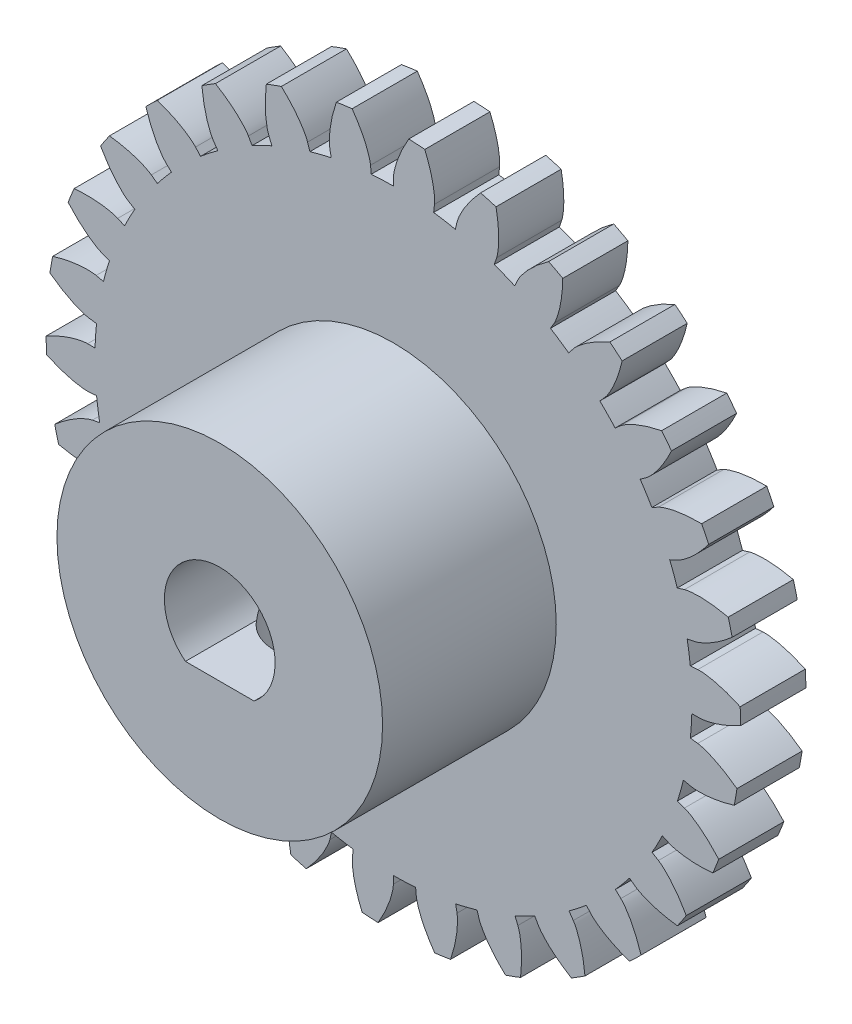
from build123d import *

# Parameters (mm, degrees)
EXTRUDE_1_DEPTH          = 3
SKETCH_4_R               = 7.5
EXTRUDE_2_DEPTH          = 8
CUT_EXTRUDE_1_DEPTH      = 15
CUT_EXTRUDE_1_DEPTH_BACK = 4.0000001
CUT_EXTRUDE_2_REACH      = 25.484
SKETCH_6_R               = 2


with BuildPart() as part:
    # 草图2 → 凸台-拉伸1 (new body)
    with BuildSketch(Plane.XY):
        with BuildLine():
            Line((1.89051353, 13.968033449), (1.851773853, 13.624736093))
            ThreePointArc((1.851773853, 13.624736093), (2.353137788, 13.547148872), (2.851298212, 13.451118857))
            Line((2.851298212, 13.451118857), (2.930596225, 13.787371237))
            add(Edge.make_bspline(
                [(2.930596225, 13.787371237), (2.933219885, 13.79849651), (2.941339291, 13.829509854), (2.959683399, 13.887352304), (2.993800918, 13.98038017), (3.04335636, 14.096749327), (3.114269634, 14.244351202), (3.206492503, 14.414330406), (3.316759861, 14.596676231), (3.446131284, 14.78988522), (3.583347507, 14.977782742), (3.727632125, 15.160449042), (3.854396241, 15.310151049), (3.946384196, 15.413194585), (4.000432021, 15.472051391), (4.015191609, 15.488002981)],
                knots=[0, 0, 0, 0, 0, 0.005376748, 0.015083688, 0.02853182, 0.046610139, 0.064854849, 0.092110525, 0.119476175, 0.146842495, 0.174208853, 0.201574955, 0.228941013, 0.239165463, 0.239165463, 0.239165463, 0.239165463, 0.239165463], degree=4))
            ThreePointArc((4.015191609, 15.488002981), (4.370978567, 15.391378963), (4.724444799, 15.28658305))
            add(Edge.make_bspline(
                [(4.753318726, 13.269738541), (4.756933997, 13.280582207), (4.766326776, 13.311233928), (4.781122088, 13.370084197), (4.800991416, 13.467158389), (4.819995031, 13.59220392), (4.837244285, 13.755045774), (4.848125921, 13.948124973), (4.850156172, 14.16120892), (4.841643416, 14.393575465), (4.823665136, 14.625546481), (4.796924027, 14.856782165), (4.767762618, 15.050765268), (4.743663456, 15.18677624), (4.728617371, 15.26525494), (4.724444799, 15.28658305)],
                knots=[0, 0, 0, 0, 0, 0.005376748, 0.015083688, 0.02853182, 0.046610139, 0.064854849, 0.092110525, 0.119476175, 0.146842495, 0.174208853, 0.201574955, 0.228941013, 0.239165463, 0.239165463, 0.239165463, 0.239165463, 0.239165463], degree=4))
            Line((4.753318726, 13.269738541), (4.644050069, 12.941997487))
            ThreePointArc((4.644050069, 12.941997487), (5.118326709, 12.76186631), (5.58563537, 12.564361405))
            Line((5.58563537, 12.564361405), (5.733111332, 12.876778879))
            add(Edge.make_bspline(
                [(5.733111332, 12.876778879), (5.737990733, 12.887115549), (5.752380747, 12.915763058), (5.782350115, 12.968527557), (5.835063664, 13.05242911), (5.907730709, 13.155952166), (6.007782513, 13.285584887), (6.133330755, 13.432675425), (6.279100336, 13.588110684), (6.44581509, 13.750199761), (6.619098901, 13.905462414), (6.798209014, 14.054138558), (6.953327827, 14.174213476), (7.06472958, 14.255879892), (7.129833348, 14.302213361), (7.147586926, 14.31474768)],
                knots=[0, 0, 0, 0, 0, 0.005376748, 0.015083688, 0.02853182, 0.046610139, 0.064854849, 0.092110525, 0.119476175, 0.146842495, 0.174208853, 0.201574955, 0.228941013, 0.239165463, 0.239165463, 0.239165463, 0.239165463, 0.239165463], degree=4))
            ThreePointArc((7.147586926, 14.31474768), (7.475509822, 14.14626286), (7.799463673, 13.970267227))
            add(Edge.make_bspline(
                [(7.408381084, 11.991492383), (7.414171878, 12.001347432), (7.429732253, 12.02937647), (7.456439911, 12.083864601), (7.496057906, 12.174686424), (7.540644674, 12.293048337), (7.591373716, 12.448745383), (7.642160985, 12.63534292), (7.688449514, 12.843348358), (7.728434503, 13.072407039), (7.759078578, 13.303046825), (7.780998428, 13.534789244), (7.792805621, 13.730596348), (7.797511354, 13.868645652), (7.799110701, 13.948537661), (7.799463673, 13.970267227)],
                knots=[0, 0, 0, 0, 0, 0.005376748, 0.015083688, 0.02853182, 0.046610139, 0.064854849, 0.092110525, 0.119476175, 0.146842495, 0.174208853, 0.201574955, 0.228941013, 0.239165463, 0.239165463, 0.239165463, 0.239165463, 0.239165463], degree=4))
            Line((7.408381084, 11.991492383), (7.233359013, 11.693631488))
            ThreePointArc((7.233359013, 11.693631488), (7.659820192, 11.418828951), (8.075853459, 11.128481069))
            Line((8.075853459, 11.128481069), (8.285061963, 11.403409496))
            add(Edge.make_bspline(
                [(8.285061963, 11.403409496), (8.291983852, 11.412505799), (8.312015562, 11.437535439), (8.352300383, 11.482915926), (8.421306129, 11.554024265), (8.513908878, 11.640176765), (8.638726469, 11.746174761), (8.792113022, 11.86394807), (8.967013995, 11.985679496), (9.163785847, 12.109564592), (9.365563911, 12.225406653), (9.571671547, 12.333594781), (9.748365621, 12.418794758), (9.874312381, 12.47551484), (9.947626746, 12.507299978), (9.967598396, 12.515869215)],
                knots=[0, 0, 0, 0, 0, 0.005376748, 0.015083688, 0.02853182, 0.046610139, 0.064854849, 0.092110525, 0.119476175, 0.146842495, 0.174208853, 0.201574955, 0.228941013, 0.239165463, 0.239165463, 0.239165463, 0.239165463, 0.239165463], degree=4))
            ThreePointArc((9.967598396, 12.515869215), (10.253325427, 12.282887189), (10.53360856, 12.04338369))
            add(Edge.make_bspline(
                [(9.739661639, 10.189160466), (9.74737487, 10.197596185), (9.768422779, 10.221777537), (9.80587553, 10.269522138), (9.863510695, 10.350122241), (9.931731961, 10.456627552), (10.013723688, 10.598375084), (10.102196942, 10.77033575), (10.190720718, 10.964171844), (10.277455917, 11.179911696), (10.355383053, 11.399140188), (10.425005861, 11.621261086), (10.477265624, 11.810334482), (10.510570589, 11.9443887), (10.52874547, 12.022202354), (10.53360856, 12.04338369)],
                knots=[0, 0, 0, 0, 0, 0.005376748, 0.015083688, 0.02853182, 0.046610139, 0.064854849, 0.092110525, 0.119476175, 0.146842495, 0.174208853, 0.201574955, 0.228941013, 0.239165463, 0.239165463, 0.239165463, 0.239165463, 0.239165463], degree=4))
            Line((9.739661639, 10.189160466), (9.506535458, 9.934197682))
            ThreePointArc((9.506535458, 9.934197682), (9.866542778, 9.576733974), (10.213118, 9.20623271))
            Line((10.213118, 9.20623271), (10.47491563, 9.431656397))
            add(Edge.make_bspline(
                [(10.47491563, 9.431656397), (10.483577487, 9.439114783), (10.508375411, 9.459432639), (10.557215046, 9.495445767), (10.639497106, 9.550653118), (10.747988375, 9.615669785), (10.892116624, 9.693400433), (11.066637761, 9.776709256), (11.263026115, 9.859416601), (11.481255189, 9.939683342), (11.702708837, 10.011041958), (11.926806103, 10.074013728), (12.117353059, 10.120615118), (12.252340349, 10.149909926), (12.33066112, 10.165757569), (12.351977987, 10.169987208)],
                knots=[0, 0, 0, 0, 0, 0.005376748, 0.015083688, 0.02853182, 0.046610139, 0.064854849, 0.092110525, 0.119476175, 0.146842495, 0.174208853, 0.201574955, 0.228941013, 0.239165463, 0.239165463, 0.239165463, 0.239165463, 0.239165463], degree=4))
            ThreePointArc((12.351977987, 10.169987208), (12.583021509, 9.882690408), (12.807384206, 9.590146495))
            add(Edge.make_bspline(
                [(11.645272245, 7.941513344), (11.654570808, 7.948161051), (11.680186355, 7.967437877), (11.726747334, 8.006352279), (11.799880737, 8.073208052), (11.888754904, 8.163201967), (11.998425883, 8.284804936), (12.120718417, 8.434613225), (12.247608527, 8.605808408), (12.377303191, 8.798800565), (12.499107599, 8.997036426), (12.613390512, 9.199828053), (12.703818843, 9.373904326), (12.764267455, 9.498104647), (12.798223539, 9.570439115), (12.807384206, 9.590146495)],
                knots=[0, 0, 0, 0, 0, 0.005376748, 0.015083688, 0.02853182, 0.046610139, 0.064854849, 0.092110525, 0.119476175, 0.146842495, 0.174208853, 0.201574955, 0.228941013, 0.239165463, 0.239165463, 0.239165463, 0.239165463, 0.239165463], degree=4))
            Line((11.645272245, 7.941513344), (11.364230687, 7.740591767))
            ThreePointArc((11.364230687, 7.740591767), (11.642050099, 7.316089769), (11.904020277, 6.881627805))
            Line((11.904020277, 6.881627805), (12.20696522, 7.047694656))
            add(Edge.make_bspline(
                [(12.20696522, 7.047694656), (12.216988481, 7.053189157), (12.24546883, 7.06790724), (12.300728752, 7.092979065), (12.392691005, 7.1298726), (12.512329205, 7.170911894), (12.669469016, 7.216977993), (12.857497326, 7.262181333), (13.066789947, 7.30224989), (13.296938586, 7.335390234), (13.528389232, 7.35914669), (13.760682002, 7.374149935), (13.956754023, 7.380116033), (14.09488225, 7.380705244), (14.174786435, 7.379922773), (14.196516868, 7.379627959)],
                knots=[0, 0, 0, 0, 0, 0.005376748, 0.015083688, 0.02853182, 0.046610139, 0.064854849, 0.092110525, 0.119476175, 0.146842495, 0.174208853, 0.201574955, 0.228941013, 0.239165463, 0.239165463, 0.239165463, 0.239165463, 0.239165463], degree=4))
            ThreePointArc((14.196516868, 7.379627959), (14.362779172, 7.050572634), (14.521415706, 6.71777388))
            add(Edge.make_bspline(
                [(13.041928573, 5.346783981), (13.052406077, 5.35135314), (13.08146974, 5.364882949), (13.135104009, 5.393266406), (13.220539368, 5.44345593), (13.326182208, 5.513005285), (13.458739293, 5.609149059), (13.609506336, 5.730257629), (13.769217072, 5.871329849), (13.936202922, 6.033139627), (14.096561165, 6.201718999), (14.250509472, 6.376318389), (14.37515422, 6.527789571), (14.460104583, 6.636707843), (14.508357827, 6.700401763), (14.521415706, 6.71777388)],
                knots=[0, 0, 0, 0, 0, 0.005376748, 0.015083688, 0.02853182, 0.046610139, 0.064854849, 0.092110525, 0.119476175, 0.146842495, 0.174208853, 0.201574955, 0.228941013, 0.239165463, 0.239165463, 0.239165463, 0.239165463, 0.239165463], degree=4))
            Line((13.041928573, 5.346783981), (12.725254503, 5.208684848))
            ThreePointArc((12.725254503, 5.208684848), (12.908743966, 4.735697333), (13.074659745, 4.256262743))
            Line((13.074659745, 4.256262743), (13.405511855, 4.35571484))
            add(Edge.make_bspline(
                [(13.405511855, 4.35571484), (13.416458454, 4.35900532), (13.4473765, 4.36748038), (13.506641586, 4.380515141), (13.604264841, 4.397482436), (13.729821208, 4.412750743), (13.893104818, 4.425138984), (14.086422561, 4.430261238), (14.299472357, 4.425939818), (14.531481961, 4.410505374), (14.7628141, 4.385621399), (14.993150066, 4.352000404), (15.186177865, 4.317070463), (15.321410162, 4.288928325), (15.399405564, 4.271549939), (15.42059984, 4.266743556)],
                knots=[0, 0, 0, 0, 0, 0.005376748, 0.015083688, 0.02853182, 0.046610139, 0.064854849, 0.092110525, 0.119476175, 0.146842495, 0.174208853, 0.201574955, 0.228941013, 0.239165463, 0.239165463, 0.239165463, 0.239165463, 0.239165463], degree=4))
            ThreePointArc((15.42059984, 4.266743556), (15.514814464, 3.910311003), (15.600791658, 3.55180231))
            add(Edge.make_bspline(
                [(13.868590041, 2.518374502), (13.879788567, 2.520665418), (13.911030125, 2.527856893), (13.969393609, 2.544468912), (14.06339699, 2.575798665), (14.181191404, 2.621863817), (14.330841213, 2.688346451), (14.503493523, 2.775462278), (14.689044759, 2.880246003), (14.886023712, 3.003801538), (15.077927365, 3.135356693), (15.264812787, 3.274133015), (15.418226377, 3.396379087), (15.523965753, 3.48525506), (15.584407258, 3.537524702), (15.600791658, 3.55180231)],
                knots=[0, 0, 0, 0, 0, 0.005376748, 0.015083688, 0.02853182, 0.046610139, 0.064854849, 0.092110525, 0.119476175, 0.146842495, 0.174208853, 0.201574955, 0.228941013, 0.239165463, 0.239165463, 0.239165463, 0.239165463, 0.239165463], degree=4))
            Line((13.868590041, 2.518374502), (13.530123634, 2.449133407))
            ThreePointArc((13.530123634, 2.449133407), (13.611263778, 1.9483322), (13.673873844, 1.444878576))
            Line((13.673873844, 1.444878576), (14.018173294, 1.473369384))
            add(Edge.make_bspline(
                [(14.018173294, 1.473369384), (14.029564813, 1.474312033), (14.061569291, 1.47617367), (14.122249371, 1.476601686), (14.221267023, 1.472901189), (14.347254141, 1.46173121), (14.509545273, 1.439900166), (14.699703536, 1.404717469), (14.907199209, 1.356194938), (15.130929845, 1.292860264), (15.352033153, 1.220423409), (15.570345527, 1.139647573), (15.751892862, 1.065348199), (15.87831893, 1.009704658), (15.950996776, 0.976489876), (15.970728602, 0.967381987)],
                knots=[0, 0, 0, 0, 0, 0.005376748, 0.015083688, 0.02853182, 0.046610139, 0.064854849, 0.092110525, 0.119476175, 0.146842495, 0.174208853, 0.201574955, 0.228941013, 0.239165463, 0.239165463, 0.239165463, 0.239165463, 0.239165463], degree=4))
            ThreePointArc((15.970728602, 0.967381987), (15.988777916, 0.599150018), (15.998338153, 0.230599937))
            add(Edge.make_bspline(
                [(14.089127575, -0.420100028), (14.100557695, -0.420187478), (14.132611741, -0.41964864), (14.193153676, -0.415534084), (14.291616679, -0.404433363), (14.416414487, -0.383865681), (14.576616605, -0.349949796), (14.763608446, -0.300634093), (14.966890705, -0.236718416), (15.185253835, -0.156817092), (15.400315787, -0.068035746), (15.611970534, 0.028852316), (15.787448057, 0.11653054), (15.909355128, 0.181479907), (15.979343311, 0.220040836), (15.998338153, 0.230599937)],
                knots=[0, 0, 0, 0, 0, 0.005376748, 0.015083688, 0.02853182, 0.046610139, 0.064854849, 0.092110525, 0.119476175, 0.146842495, 0.174208853, 0.201574955, 0.228941013, 0.239165463, 0.239165463, 0.239165463, 0.239165463, 0.239165463], degree=4))
            Line((14.089127575, -0.420100028), (13.743661438, -0.417456916))
            ThreePointArc((13.743661438, -0.417456916), (13.71890605, -0.924184399), (13.675474041, -1.429653718))
            Line((13.675474041, -1.429653718), (14.018173294, -1.473369384))
            add(Edge.make_bspline(
                [(14.018173294, -1.473369384), (14.029511869, -1.474815764), (14.061204028, -1.479648913), (14.120647093, -1.491846349), (14.216731594, -1.516052908), (14.337643222, -1.553172991), (14.491848974, -1.608269198), (14.670536929, -1.682219195), (14.863409923, -1.772822168), (15.069083489, -1.881289042), (15.270294689, -1.998112941), (15.467042173, -2.122513326), (15.629174555, -2.232934894), (15.741268968, -2.313647947), (15.805452887, -2.36124748), (15.822859889, -2.374258818)],
                knots=[0, 0, 0, 0, 0, 0.005376748, 0.015083688, 0.02853182, 0.046610139, 0.064854849, 0.092110525, 0.119476175, 0.146842495, 0.174208853, 0.201574955, 0.228941013, 0.239165463, 0.239165463, 0.239165463, 0.239165463, 0.239165463], degree=4))
            ThreePointArc((15.822859889, -2.374258818), (15.763955051, -2.738196698), (15.696680503, -3.100680761))
            add(Edge.make_bspline(
                [(13.693902627, -3.340214171), (13.705064789, -3.342676165), (13.736530409, -3.348813513), (13.796604821, -3.357376246), (13.895224141, -3.366989712), (14.021571079, -3.372818406), (14.185323905, -3.372951558), (14.378482837, -3.363591311), (14.590611707, -3.343337103), (14.820815499, -3.310582062), (15.049636511, -3.268454696), (15.276810254, -3.217689367), (15.4666825, -3.168410951), (15.599429342, -3.130226789), (15.675905383, -3.10705987), (15.696680503, -3.100680761)],
                knots=[0, 0, 0, 0, 0, 0.005376748, 0.015083688, 0.02853182, 0.046610139, 0.064854849, 0.092110525, 0.119476175, 0.146842495, 0.174208853, 0.201574955, 0.228941013, 0.239165463, 0.239165463, 0.239165463, 0.239165463, 0.239165463], degree=4))
            Line((13.693902627, -3.340214171), (13.356535288, -3.265802368))
            ThreePointArc((13.356535288, -3.265802368), (13.226966296, -3.756309706), (13.0793904, -4.241703285))
            Line((13.0793904, -4.241703285), (13.405511855, -4.35571484))
            add(Edge.make_bspline(
                [(13.405511855, -4.35571484), (13.416301935, -4.359487035), (13.446296676, -4.370803739), (13.501904778, -4.395093539), (13.590856776, -4.438748218), (13.701408495, -4.50019608), (13.840789336, -4.58614948), (14.000197462, -4.695634808), (14.1700183, -4.824358438), (14.348645874, -4.97321699), (14.521171072, -5.129322167), (14.687754858, -5.291910207), (14.823386324, -5.433628017), (14.916250017, -5.535883035), (14.969134863, -5.595786991), (14.983456272, -5.61213312)],
                knots=[0, 0, 0, 0, 0, 0.005376748, 0.015083688, 0.02853182, 0.046610139, 0.064854849, 0.092110525, 0.119476175, 0.146842495, 0.174208853, 0.201574955, 0.228941013, 0.239165463, 0.239165463, 0.239165463, 0.239165463, 0.239165463], degree=4))
            ThreePointArc((14.983456272, -5.61213312), (14.850171706, -5.955871079), (14.709002594, -6.296446831))
            add(Edge.make_bspline(
                [(12.700188423, -6.114344926), (12.710594788, -6.119073864), (12.740096782, -6.131619166), (12.797078132, -6.152484956), (12.891543631, -6.182392454), (13.013917731, -6.214362782), (13.174064482, -6.248539152), (13.364948533, -6.279543449), (13.576652965, -6.303835916), (13.808636407, -6.319658711), (14.041215903, -6.326026492), (14.27398006, -6.323602585), (14.469948701, -6.31487768), (14.607733639, -6.305127553), (14.687355169, -6.29836715), (14.709002594, -6.296446831)],
                knots=[0, 0, 0, 0, 0, 0.005376748, 0.015083688, 0.02853182, 0.046610139, 0.064854849, 0.092110525, 0.119476175, 0.146842495, 0.174208853, 0.201574955, 0.228941013, 0.239165463, 0.239165463, 0.239165463, 0.239165463, 0.239165463], degree=4))
            Line((12.700188423, -6.114344926), (12.385664454, -5.971416586))
            ThreePointArc((12.385664454, -5.971416586), (12.156944645, -6.424266253), (11.911674637, -6.868370064))
            Line((11.911674637, -6.868370064), (12.20696522, -7.047694656))
            add(Edge.make_bspline(
                [(12.20696522, -7.047694656), (12.216735228, -7.053627803), (12.243721637, -7.070933468), (12.293064435, -7.106254052), (12.3709963, -7.167448932), (12.466356471, -7.250539005), (12.584820789, -7.363593024), (12.717982185, -7.503828647), (12.857328883, -7.665047095), (13.001103582, -7.847791491), (13.1374026, -8.036355402), (13.266542176, -8.230025219), (13.369744979, -8.396845522), (13.439319364, -8.51617347), (13.478593817, -8.585763759), (13.489203717, -8.604730274)],
                knots=[0, 0, 0, 0, 0, 0.005376748, 0.015083688, 0.02853182, 0.046610139, 0.064854849, 0.092110525, 0.119476175, 0.146842495, 0.174208853, 0.201574955, 0.228941013, 0.239165463, 0.239165463, 0.239165463, 0.239165463, 0.239165463], degree=4))
            ThreePointArc((13.489203717, -8.604730274), (13.287364598, -8.913245315), (13.07847069, -9.21702796))
            add(Edge.make_bspline(
                [(11.151415043, -8.621249468), (11.160610802, -8.628038673), (11.186859792, -8.646443639), (11.238257721, -8.67870055), (11.324440804, -8.727594979), (11.437493732, -8.784309685), (11.587035225, -8.851035601), (11.767301845, -8.921049405), (11.969329339, -8.98882685), (12.192953643, -9.052535949), (12.419126783, -9.107120575), (12.647308444, -9.153144025), (12.840808709, -9.185353952), (12.977609881, -9.204463988), (13.056897056, -9.214405563), (13.07847069, -9.21702796)],
                knots=[0, 0, 0, 0, 0, 0.005376748, 0.015083688, 0.02853182, 0.046610139, 0.064854849, 0.092110525, 0.119476175, 0.146842495, 0.174208853, 0.201574955, 0.228941013, 0.239165463, 0.239165463, 0.239165463, 0.239165463, 0.239165463], degree=4))
            Line((11.151415043, -8.621249468), (10.87348065, -8.416051245))
            ThreePointArc((10.87348065, -8.416051245), (10.555606178, -8.811451538), (10.223361534, -9.194856114))
            Line((10.223361534, -9.194856114), (10.47491563, -9.431656397))
            add(Edge.make_bspline(
                [(10.47491563, -9.431656397), (10.483238569, -9.43949119), (10.50603721, -9.462029474), (10.546958187, -9.506837163), (10.610463923, -9.582897734), (10.686464848, -9.683998584), (10.778835184, -9.819212218), (10.879930058, -9.984069167), (10.982712497, -10.170736413), (11.085350678, -10.379379846), (11.179466593, -10.592161342), (11.26551794, -10.808448637), (11.331781623, -10.993080586), (11.375025966, -11.12426626), (11.398973543, -11.200501452), (11.405408231, -11.221259425)],
                knots=[0, 0, 0, 0, 0, 0.005376748, 0.015083688, 0.02853182, 0.046610139, 0.064854849, 0.092110525, 0.119476175, 0.146842495, 0.174208853, 0.201574955, 0.228941013, 0.239165463, 0.239165463, 0.239165463, 0.239165463, 0.239165463], degree=4))
            ThreePointArc((11.405408231, -11.221259425), (11.143835897, -11.481067959), (10.876346859, -11.734780739))
            add(Edge.make_bspline(
                [(9.115271315, -10.751364039), (9.12285457, -10.759916789), (9.144703349, -10.783377035), (9.188271521, -10.825615285), (9.262405573, -10.891359724), (9.361196373, -10.970340103), (9.493596927, -11.066699322), (9.655367601, -11.172662695), (9.838888587, -11.280962918), (10.044380296, -11.389773927), (10.254262228, -11.490189788), (10.467888759, -11.58264915), (10.650463759, -11.65438618), (10.780302297, -11.701521179), (10.855789888, -11.727730238), (10.876346859, -11.734780739)],
                knots=[0, 0, 0, 0, 0, 0.005376748, 0.015083688, 0.02853182, 0.046610139, 0.064854849, 0.092110525, 0.119476175, 0.146842495, 0.174208853, 0.201574955, 0.228941013, 0.239165463, 0.239165463, 0.239165463, 0.239165463, 0.239165463], degree=4))
            Line((9.115271315, -10.751364039), (8.886073565, -10.49286408))
            ThreePointArc((8.886073565, -10.49286408), (8.492937069, -10.813534109), (8.088238474, -11.119482829))
            Line((8.088238474, -11.119482829), (8.285061963, -11.403409496))
            add(Edge.make_bspline(
                [(8.285061963, -11.403409496), (8.29157408, -11.412803516), (8.309188544, -11.439589388), (8.339899257, -11.491925871), (8.386203358, -11.579527921), (8.439523432, -11.694220956), (8.501762759, -11.84568472), (8.566372781, -12.027957956), (8.628098874, -12.231915745), (8.685114755, -12.457339497), (8.732934252, -12.685039005), (8.772136513, -12.914490985), (8.798565035, -13.108865277), (8.81358935, -13.246175233), (8.821163427, -13.325723485), (8.823141677, -13.347365693)],
                knots=[0, 0, 0, 0, 0, 0.005376748, 0.015083688, 0.02853182, 0.046610139, 0.064854849, 0.092110525, 0.119476175, 0.146842495, 0.174208853, 0.201574955, 0.228941013, 0.239165463, 0.239165463, 0.239165463, 0.239165463, 0.239165463], degree=4))
            ThreePointArc((8.823141677, -13.347365693), (8.513268094, -13.547112842), (8.19887448, -13.739667291))
            add(Edge.make_bspline(
                [(6.680746491, -12.411592411), (6.686385817, -12.42153491), (6.702879488, -12.44902511), (6.736713765, -12.499398685), (6.795558773, -12.579119787), (6.875769812, -12.676914017), (6.985242889, -12.798695179), (7.121447462, -12.935977012), (7.278441191, -13.080066774), (7.456819333, -13.22922413), (7.641237209, -13.371082571), (7.830972106, -13.505936928), (7.994642436, -13.614065809), (8.111843774, -13.687165745), (8.180232609, -13.728496825), (8.19887448, -13.739667291)],
                knots=[0, 0, 0, 0, 0, 0.005376748, 0.015083688, 0.02853182, 0.046610139, 0.064854849, 0.092110525, 0.119476175, 0.146842495, 0.174208853, 0.201574955, 0.228941013, 0.239165463, 0.239165463, 0.239165463, 0.239165463, 0.239165463], degree=4))
            Line((6.680746491, -12.411592411), (6.510302425, -12.111088404))
            ThreePointArc((6.510302425, -12.111088404), (6.059085857, -12.343013351), (5.599620582, -12.558134787))
            Line((5.599620582, -12.558134787), (5.733111332, -12.876778879))
            add(Edge.make_bspline(
                [(5.733111332, -12.876778879), (5.737528017, -12.887321563), (5.749188466, -12.917184352), (5.76834671, -12.974762275), (5.795425465, -13.070077174), (5.823734344, -13.193349757), (5.853122506, -13.354443958), (5.878423907, -13.546167266), (5.896395928, -13.758501664), (5.905297642, -13.990853634), (5.904730778, -14.223519594), (5.895370627, -14.456108107), (5.880808934, -14.651729652), (5.866956586, -14.789162787), (5.857826141, -14.868547458), (5.855261493, -14.890128033)],
                knots=[0, 0, 0, 0, 0, 0.005376748, 0.015083688, 0.02853182, 0.046610139, 0.064854849, 0.092110525, 0.119476175, 0.146842495, 0.174208853, 0.201574955, 0.228941013, 0.239165463, 0.239165463, 0.239165463, 0.239165463, 0.239165463], degree=4))
            ThreePointArc((5.855261493, -14.890128033), (5.510629624, -15.021083887), (5.163071944, -15.144064451))
            add(Edge.make_bspline(
                [(3.954240987, -13.529374637), (3.957689919, -13.54027235), (3.96810763, -13.57059105), (3.990729291, -13.626898384), (4.031713446, -13.717111953), (4.089839117, -13.829445958), (4.171600217, -13.971326642), (4.276285895, -14.133927061), (4.399890989, -14.307508947), (4.543359582, -14.490493758), (4.694253458, -14.667594884), (4.851804394, -14.838950453), (4.989416877, -14.978745433), (5.088858752, -15.074615489), (5.147159913, -15.129262224), (5.163071944, -15.144064451)],
                knots=[0, 0, 0, 0, 0, 0.005376748, 0.015083688, 0.02853182, 0.046610139, 0.064854849, 0.092110525, 0.119476175, 0.146842495, 0.174208853, 0.201574955, 0.228941013, 0.239165463, 0.239165463, 0.239165463, 0.239165463, 0.239165463], degree=4))
            Line((3.954240987, -13.529374637), (3.849999829, -13.20000005))
            ThreePointArc((3.849999829, -13.20000005), (3.360423518, -13.33304368), (2.8662724, -13.447935995))
            Line((2.8662724, -13.447935995), (2.930596225, -13.787371237))
            add(Edge.make_bspline(
                [(2.930596225, -13.787371237), (2.932724448, -13.798601818), (2.937921265, -13.830236377), (2.944689732, -13.890539307), (2.95135967, -13.989401336), (2.953420121, -14.115865864), (2.948672713, -14.279549914), (2.9335597, -14.472344064), (2.906992185, -14.683775039), (2.867390685, -14.912900332), (2.818462235, -15.140364125), (2.760948755, -15.365923935), (2.706033264, -15.554243135), (2.663909668, -15.685792961), (2.638473743, -15.76154456), (2.631478285, -15.782120328)],
                knots=[0, 0, 0, 0, 0, 0.005376748, 0.015083688, 0.02853182, 0.046610139, 0.064854849, 0.092110525, 0.119476175, 0.146842495, 0.174208853, 0.201574955, 0.228941013, 0.239165463, 0.239165463, 0.239165463, 0.239165463, 0.239165463], degree=4))
            ThreePointArc((2.631478285, -15.782120328), (2.267150196, -15.838561487), (1.901618388, -15.886593326))
            add(Edge.make_bspline(
                [(1.054916178, -14.05585827), (1.05602398, -14.067234916), (1.059910427, -14.099057043), (1.070330798, -14.158837234), (1.091662894, -14.255600505), (1.125162828, -14.377564749), (1.175638599, -14.533344088), (1.244230116, -14.714156674), (1.329044438, -14.909644324), (1.431333217, -15.118459276), (1.542108304, -15.323062918), (1.660589549, -15.523430638), (1.766129858, -15.688782007), (1.843466184, -15.8032322), (1.88913163, -15.868806266), (1.901618388, -15.886593326)],
                knots=[0, 0, 0, 0, 0, 0.005376748, 0.015083688, 0.02853182, 0.046610139, 0.064854849, 0.092110525, 0.119476175, 0.146842495, 0.174208853, 0.201574955, 0.228941013, 0.239165463, 0.239165463, 0.239165463, 0.239165463, 0.239165463], degree=4))
            Line((1.054916178, -14.05585827), (1.021433767, -13.712008353))
            ThreePointArc((1.021433767, -13.712008353), (0.514894547, -13.740356022), (0.00765436, -13.749997869))
            Line((0.00765436, -13.749997869), (0, -14.095389312))
            add(Edge.make_bspline(
                [(0, -14.095389312), (-0.000253253, -14.10681696), (-0.001747193, -14.138840708), (-0.007664317, -14.199233117), (-0.021694705, -14.297321532), (-0.045972734, -14.421450899), (-0.084648228, -14.580571017), (-0.139515142, -14.76600998), (-0.209461064, -14.967296985), (-0.295835004, -15.183181725), (-0.390986632, -15.395502092), (-0.494139826, -15.604175154), (-0.587009045, -15.776961555), (-0.655562886, -15.896878714), (-0.696192618, -15.965686532), (-0.707313151, -15.984358233)],
                knots=[0, 0, 0, 0, 0, 0.005376748, 0.015083688, 0.02853182, 0.046610139, 0.064854849, 0.092110525, 0.119476175, 0.146842495, 0.174208853, 0.201574955, 0.228941013, 0.239165463, 0.239165463, 0.239165463, 0.239165463, 0.239165463], degree=4))
            ThreePointArc((-0.707313151, -15.984358233), (-1.075414574, -15.963817949), (-1.442945016, -15.93480184))
            add(Edge.make_bspline(
                [(-1.89051353, -13.968033449), (-1.891795274, -13.979391813), (-1.894609948, -14.011326588), (-1.896846287, -14.071966956), (-1.896098564, -14.17105091), (-1.888688476, -14.29731497), (-1.871704068, -14.46018466), (-1.842204491, -14.651307035), (-1.799887733, -14.860156699), (-1.743249279, -15.085675576), (-1.677434382, -15.308839574), (-1.603201028, -15.529462414), (-1.534345511, -15.713143523), (-1.482494702, -15.841171832), (-1.451460771, -15.914807327), (-1.442945016, -15.93480184)],
                knots=[0, 0, 0, 0, 0, 0.005376748, 0.015083688, 0.02853182, 0.046610139, 0.064854849, 0.092110525, 0.119476175, 0.146842495, 0.174208853, 0.201574955, 0.228941013, 0.239165463, 0.239165463, 0.239165463, 0.239165463, 0.239165463], degree=4))
            Line((-1.89051353, -13.968033449), (-1.851773853, -13.624736093))
            ThreePointArc((-1.851773853, -13.624736093), (-2.353137788, -13.547148872), (-2.851298212, -13.451118857))
            Line((-2.851298212, -13.451118857), (-2.930596225, -13.787371237))
            add(Edge.make_bspline(
                [(-2.930596225, -13.787371237), (-2.933219885, -13.79849651), (-2.941339291, -13.829509854), (-2.959683399, -13.887352304), (-2.993800918, -13.98038017), (-3.04335636, -14.096749327), (-3.114269634, -14.244351202), (-3.206492503, -14.414330406), (-3.316759861, -14.596676231), (-3.446131284, -14.78988522), (-3.583347507, -14.977782742), (-3.727632125, -15.160449042), (-3.854396241, -15.310151049), (-3.946384196, -15.413194585), (-4.000432021, -15.472051391), (-4.015191609, -15.488002981)],
                knots=[0, 0, 0, 0, 0, 0.005376748, 0.015083688, 0.02853182, 0.046610139, 0.064854849, 0.092110525, 0.119476175, 0.146842495, 0.174208853, 0.201574955, 0.228941013, 0.239165463, 0.239165463, 0.239165463, 0.239165463, 0.239165463], degree=4))
            ThreePointArc((-4.015191609, -15.488002981), (-4.370978567, -15.391378963), (-4.724444799, -15.28658305))
            add(Edge.make_bspline(
                [(-4.753318726, -13.269738541), (-4.756933997, -13.280582207), (-4.766326776, -13.311233928), (-4.781122088, -13.370084197), (-4.800991416, -13.467158389), (-4.819995031, -13.59220392), (-4.837244285, -13.755045774), (-4.848125921, -13.948124973), (-4.850156172, -14.16120892), (-4.841643416, -14.393575465), (-4.823665136, -14.625546481), (-4.796924027, -14.856782165), (-4.767762618, -15.050765268), (-4.743663456, -15.18677624), (-4.728617371, -15.26525494), (-4.724444799, -15.28658305)],
                knots=[0, 0, 0, 0, 0, 0.005376748, 0.015083688, 0.02853182, 0.046610139, 0.064854849, 0.092110525, 0.119476175, 0.146842495, 0.174208853, 0.201574955, 0.228941013, 0.239165463, 0.239165463, 0.239165463, 0.239165463, 0.239165463], degree=4))
            Line((-4.753318726, -13.269738541), (-4.644050069, -12.941997487))
            ThreePointArc((-4.644050069, -12.941997487), (-5.118326709, -12.76186631), (-5.58563537, -12.564361405))
            Line((-5.58563537, -12.564361405), (-5.733111332, -12.876778879))
            add(Edge.make_bspline(
                [(-5.733111332, -12.876778879), (-5.737990733, -12.887115549), (-5.752380747, -12.915763058), (-5.782350115, -12.968527557), (-5.835063664, -13.05242911), (-5.907730709, -13.155952166), (-6.007782513, -13.285584887), (-6.133330755, -13.432675425), (-6.279100336, -13.588110684), (-6.44581509, -13.750199761), (-6.619098901, -13.905462414), (-6.798209014, -14.054138558), (-6.953327827, -14.174213476), (-7.06472958, -14.255879892), (-7.129833348, -14.302213361), (-7.147586926, -14.31474768)],
                knots=[0, 0, 0, 0, 0, 0.005376748, 0.015083688, 0.02853182, 0.046610139, 0.064854849, 0.092110525, 0.119476175, 0.146842495, 0.174208853, 0.201574955, 0.228941013, 0.239165463, 0.239165463, 0.239165463, 0.239165463, 0.239165463], degree=4))
            ThreePointArc((-7.147586926, -14.31474768), (-7.475509822, -14.14626286), (-7.799463673, -13.970267227))
            add(Edge.make_bspline(
                [(-7.408381084, -11.991492383), (-7.414171878, -12.001347432), (-7.429732253, -12.02937647), (-7.456439911, -12.083864601), (-7.496057906, -12.174686424), (-7.540644674, -12.293048337), (-7.591373716, -12.448745383), (-7.642160985, -12.63534292), (-7.688449514, -12.843348358), (-7.728434503, -13.072407039), (-7.759078578, -13.303046825), (-7.780998428, -13.534789244), (-7.792805621, -13.730596348), (-7.797511354, -13.868645652), (-7.799110701, -13.948537661), (-7.799463673, -13.970267227)],
                knots=[0, 0, 0, 0, 0, 0.005376748, 0.015083688, 0.02853182, 0.046610139, 0.064854849, 0.092110525, 0.119476175, 0.146842495, 0.174208853, 0.201574955, 0.228941013, 0.239165463, 0.239165463, 0.239165463, 0.239165463, 0.239165463], degree=4))
            Line((-7.408381084, -11.991492383), (-7.233359013, -11.693631488))
            ThreePointArc((-7.233359013, -11.693631488), (-7.659820192, -11.418828951), (-8.075853459, -11.128481069))
            Line((-8.075853459, -11.128481069), (-8.285061963, -11.403409496))
            add(Edge.make_bspline(
                [(-8.285061963, -11.403409496), (-8.291983852, -11.412505799), (-8.312015562, -11.437535439), (-8.352300383, -11.482915926), (-8.421306129, -11.554024265), (-8.513908878, -11.640176765), (-8.638726469, -11.746174761), (-8.792113022, -11.86394807), (-8.967013995, -11.985679496), (-9.163785847, -12.109564592), (-9.365563911, -12.225406653), (-9.571671547, -12.333594781), (-9.748365621, -12.418794758), (-9.874312381, -12.47551484), (-9.947626746, -12.507299978), (-9.967598396, -12.515869215)],
                knots=[0, 0, 0, 0, 0, 0.005376748, 0.015083688, 0.02853182, 0.046610139, 0.064854849, 0.092110525, 0.119476175, 0.146842495, 0.174208853, 0.201574955, 0.228941013, 0.239165463, 0.239165463, 0.239165463, 0.239165463, 0.239165463], degree=4))
            ThreePointArc((-9.967598396, -12.515869215), (-10.253325427, -12.282887189), (-10.53360856, -12.04338369))
            add(Edge.make_bspline(
                [(-9.739661639, -10.189160466), (-9.74737487, -10.197596185), (-9.768422779, -10.221777537), (-9.80587553, -10.269522138), (-9.863510695, -10.350122241), (-9.931731961, -10.456627552), (-10.013723688, -10.598375084), (-10.102196942, -10.77033575), (-10.190720718, -10.964171844), (-10.277455917, -11.179911696), (-10.355383053, -11.399140188), (-10.425005861, -11.621261086), (-10.477265624, -11.810334482), (-10.510570589, -11.9443887), (-10.52874547, -12.022202354), (-10.53360856, -12.04338369)],
                knots=[0, 0, 0, 0, 0, 0.005376748, 0.015083688, 0.02853182, 0.046610139, 0.064854849, 0.092110525, 0.119476175, 0.146842495, 0.174208853, 0.201574955, 0.228941013, 0.239165463, 0.239165463, 0.239165463, 0.239165463, 0.239165463], degree=4))
            Line((-9.739661639, -10.189160466), (-9.506535458, -9.934197682))
            ThreePointArc((-9.506535458, -9.934197682), (-9.866542778, -9.576733974), (-10.213118, -9.20623271))
            Line((-10.213118, -9.20623271), (-10.47491563, -9.431656397))
            add(Edge.make_bspline(
                [(-10.47491563, -9.431656397), (-10.483577487, -9.439114783), (-10.508375411, -9.459432639), (-10.557215046, -9.495445767), (-10.639497106, -9.550653118), (-10.747988375, -9.615669785), (-10.892116624, -9.693400433), (-11.066637761, -9.776709256), (-11.263026115, -9.859416601), (-11.481255189, -9.939683342), (-11.702708837, -10.011041958), (-11.926806103, -10.074013728), (-12.117353059, -10.120615118), (-12.252340349, -10.149909926), (-12.33066112, -10.165757569), (-12.351977987, -10.169987208)],
                knots=[0, 0, 0, 0, 0, 0.005376748, 0.015083688, 0.02853182, 0.046610139, 0.064854849, 0.092110525, 0.119476175, 0.146842495, 0.174208853, 0.201574955, 0.228941013, 0.239165463, 0.239165463, 0.239165463, 0.239165463, 0.239165463], degree=4))
            ThreePointArc((-12.351977987, -10.169987208), (-12.583021509, -9.882690408), (-12.807384206, -9.590146495))
            add(Edge.make_bspline(
                [(-11.645272245, -7.941513344), (-11.654570808, -7.948161051), (-11.680186355, -7.967437877), (-11.726747334, -8.006352279), (-11.799880737, -8.073208052), (-11.888754904, -8.163201967), (-11.998425883, -8.284804936), (-12.120718417, -8.434613225), (-12.247608527, -8.605808408), (-12.377303191, -8.798800565), (-12.499107599, -8.997036426), (-12.613390512, -9.199828053), (-12.703818843, -9.373904326), (-12.764267455, -9.498104647), (-12.798223539, -9.570439115), (-12.807384206, -9.590146495)],
                knots=[0, 0, 0, 0, 0, 0.005376748, 0.015083688, 0.02853182, 0.046610139, 0.064854849, 0.092110525, 0.119476175, 0.146842495, 0.174208853, 0.201574955, 0.228941013, 0.239165463, 0.239165463, 0.239165463, 0.239165463, 0.239165463], degree=4))
            Line((-11.645272245, -7.941513344), (-11.364230687, -7.740591767))
            ThreePointArc((-11.364230687, -7.740591767), (-11.642050099, -7.316089769), (-11.904020277, -6.881627805))
            Line((-11.904020277, -6.881627805), (-12.20696522, -7.047694656))
            add(Edge.make_bspline(
                [(-12.20696522, -7.047694656), (-12.216988481, -7.053189157), (-12.24546883, -7.06790724), (-12.300728752, -7.092979065), (-12.392691005, -7.1298726), (-12.512329205, -7.170911894), (-12.669469016, -7.216977993), (-12.857497326, -7.262181333), (-13.066789947, -7.30224989), (-13.296938586, -7.335390234), (-13.528389232, -7.35914669), (-13.760682002, -7.374149935), (-13.956754023, -7.380116033), (-14.09488225, -7.380705244), (-14.174786435, -7.379922773), (-14.196516868, -7.379627959)],
                knots=[0, 0, 0, 0, 0, 0.005376748, 0.015083688, 0.02853182, 0.046610139, 0.064854849, 0.092110525, 0.119476175, 0.146842495, 0.174208853, 0.201574955, 0.228941013, 0.239165463, 0.239165463, 0.239165463, 0.239165463, 0.239165463], degree=4))
            ThreePointArc((-14.196516868, -7.379627959), (-14.362779172, -7.050572634), (-14.521415706, -6.71777388))
            add(Edge.make_bspline(
                [(-13.041928573, -5.346783981), (-13.052406077, -5.35135314), (-13.08146974, -5.364882949), (-13.135104009, -5.393266406), (-13.220539368, -5.44345593), (-13.326182208, -5.513005285), (-13.458739293, -5.609149059), (-13.609506336, -5.730257629), (-13.769217072, -5.871329849), (-13.936202922, -6.033139627), (-14.096561165, -6.201718999), (-14.250509472, -6.376318389), (-14.37515422, -6.527789571), (-14.460104583, -6.636707843), (-14.508357827, -6.700401763), (-14.521415706, -6.71777388)],
                knots=[0, 0, 0, 0, 0, 0.005376748, 0.015083688, 0.02853182, 0.046610139, 0.064854849, 0.092110525, 0.119476175, 0.146842495, 0.174208853, 0.201574955, 0.228941013, 0.239165463, 0.239165463, 0.239165463, 0.239165463, 0.239165463], degree=4))
            Line((-13.041928573, -5.346783981), (-12.725254503, -5.208684848))
            ThreePointArc((-12.725254503, -5.208684848), (-12.908743966, -4.735697333), (-13.074659745, -4.256262743))
            Line((-13.074659745, -4.256262743), (-13.405511855, -4.35571484))
            add(Edge.make_bspline(
                [(-13.405511855, -4.35571484), (-13.416458454, -4.35900532), (-13.4473765, -4.36748038), (-13.506641586, -4.380515141), (-13.604264841, -4.397482436), (-13.729821208, -4.412750743), (-13.893104818, -4.425138984), (-14.086422561, -4.430261238), (-14.299472357, -4.425939818), (-14.531481961, -4.410505374), (-14.7628141, -4.385621399), (-14.993150066, -4.352000404), (-15.186177865, -4.317070463), (-15.321410162, -4.288928325), (-15.399405564, -4.271549939), (-15.42059984, -4.266743556)],
                knots=[0, 0, 0, 0, 0, 0.005376748, 0.015083688, 0.02853182, 0.046610139, 0.064854849, 0.092110525, 0.119476175, 0.146842495, 0.174208853, 0.201574955, 0.228941013, 0.239165463, 0.239165463, 0.239165463, 0.239165463, 0.239165463], degree=4))
            ThreePointArc((-15.42059984, -4.266743556), (-15.514814464, -3.910311003), (-15.600791658, -3.55180231))
            add(Edge.make_bspline(
                [(-13.868590041, -2.518374502), (-13.879788567, -2.520665418), (-13.911030125, -2.527856893), (-13.969393609, -2.544468912), (-14.06339699, -2.575798665), (-14.181191404, -2.621863817), (-14.330841213, -2.688346451), (-14.503493523, -2.775462278), (-14.689044759, -2.880246003), (-14.886023712, -3.003801538), (-15.077927365, -3.135356693), (-15.264812787, -3.274133015), (-15.418226377, -3.396379087), (-15.523965753, -3.48525506), (-15.584407258, -3.537524702), (-15.600791658, -3.55180231)],
                knots=[0, 0, 0, 0, 0, 0.005376748, 0.015083688, 0.02853182, 0.046610139, 0.064854849, 0.092110525, 0.119476175, 0.146842495, 0.174208853, 0.201574955, 0.228941013, 0.239165463, 0.239165463, 0.239165463, 0.239165463, 0.239165463], degree=4))
            Line((-13.868590041, -2.518374502), (-13.530123634, -2.449133407))
            ThreePointArc((-13.530123634, -2.449133407), (-13.611263778, -1.9483322), (-13.673873844, -1.444878576))
            Line((-13.673873844, -1.444878576), (-14.018173294, -1.473369384))
            add(Edge.make_bspline(
                [(-14.018173294, -1.473369384), (-14.029564813, -1.474312033), (-14.061569291, -1.47617367), (-14.122249371, -1.476601686), (-14.221267023, -1.472901189), (-14.347254141, -1.46173121), (-14.509545273, -1.439900166), (-14.699703536, -1.404717469), (-14.907199209, -1.356194938), (-15.130929845, -1.292860264), (-15.352033153, -1.220423409), (-15.570345527, -1.139647573), (-15.751892862, -1.065348199), (-15.87831893, -1.009704658), (-15.950996776, -0.976489876), (-15.970728602, -0.967381987)],
                knots=[0, 0, 0, 0, 0, 0.005376748, 0.015083688, 0.02853182, 0.046610139, 0.064854849, 0.092110525, 0.119476175, 0.146842495, 0.174208853, 0.201574955, 0.228941013, 0.239165463, 0.239165463, 0.239165463, 0.239165463, 0.239165463], degree=4))
            ThreePointArc((-15.970728602, -0.967381987), (-15.988777916, -0.599150018), (-15.998338153, -0.230599937))
            add(Edge.make_bspline(
                [(-14.089127575, 0.420100028), (-14.100557695, 0.420187478), (-14.132611741, 0.41964864), (-14.193153676, 0.415534084), (-14.291616679, 0.404433363), (-14.416414487, 0.383865681), (-14.576616605, 0.349949796), (-14.763608446, 0.300634093), (-14.966890705, 0.236718416), (-15.185253835, 0.156817092), (-15.400315787, 0.068035746), (-15.611970534, -0.028852316), (-15.787448057, -0.11653054), (-15.909355128, -0.181479907), (-15.979343311, -0.220040836), (-15.998338153, -0.230599937)],
                knots=[0, 0, 0, 0, 0, 0.005376748, 0.015083688, 0.02853182, 0.046610139, 0.064854849, 0.092110525, 0.119476175, 0.146842495, 0.174208853, 0.201574955, 0.228941013, 0.239165463, 0.239165463, 0.239165463, 0.239165463, 0.239165463], degree=4))
            Line((-14.089127575, 0.420100028), (-13.743661438, 0.417456916))
            ThreePointArc((-13.743661438, 0.417456916), (-13.71890605, 0.924184399), (-13.675474041, 1.429653718))
            Line((-13.675474041, 1.429653718), (-14.018173294, 1.473369384))
            add(Edge.make_bspline(
                [(-14.018173294, 1.473369384), (-14.029511869, 1.474815764), (-14.061204028, 1.479648913), (-14.120647093, 1.491846349), (-14.216731594, 1.516052908), (-14.337643222, 1.553172991), (-14.491848974, 1.608269198), (-14.670536929, 1.682219195), (-14.863409923, 1.772822168), (-15.069083489, 1.881289042), (-15.270294689, 1.998112941), (-15.467042173, 2.122513326), (-15.629174555, 2.232934894), (-15.741268968, 2.313647947), (-15.805452887, 2.36124748), (-15.822859889, 2.374258818)],
                knots=[0, 0, 0, 0, 0, 0.005376748, 0.015083688, 0.02853182, 0.046610139, 0.064854849, 0.092110525, 0.119476175, 0.146842495, 0.174208853, 0.201574955, 0.228941013, 0.239165463, 0.239165463, 0.239165463, 0.239165463, 0.239165463], degree=4))
            ThreePointArc((-15.822859889, 2.374258818), (-15.763955051, 2.738196698), (-15.696680503, 3.100680761))
            add(Edge.make_bspline(
                [(-13.693902627, 3.340214171), (-13.705064789, 3.342676165), (-13.736530409, 3.348813513), (-13.796604821, 3.357376246), (-13.895224141, 3.366989712), (-14.021571079, 3.372818406), (-14.185323905, 3.372951558), (-14.378482837, 3.363591311), (-14.590611707, 3.343337103), (-14.820815499, 3.310582062), (-15.049636511, 3.268454696), (-15.276810254, 3.217689367), (-15.4666825, 3.168410951), (-15.599429342, 3.130226789), (-15.675905383, 3.10705987), (-15.696680503, 3.100680761)],
                knots=[0, 0, 0, 0, 0, 0.005376748, 0.015083688, 0.02853182, 0.046610139, 0.064854849, 0.092110525, 0.119476175, 0.146842495, 0.174208853, 0.201574955, 0.228941013, 0.239165463, 0.239165463, 0.239165463, 0.239165463, 0.239165463], degree=4))
            Line((-13.693902627, 3.340214171), (-13.356535288, 3.265802368))
            ThreePointArc((-13.356535288, 3.265802368), (-13.226966296, 3.756309706), (-13.0793904, 4.241703285))
            Line((-13.0793904, 4.241703285), (-13.405511855, 4.35571484))
            add(Edge.make_bspline(
                [(-13.405511855, 4.35571484), (-13.416301935, 4.359487035), (-13.446296676, 4.370803739), (-13.501904778, 4.395093539), (-13.590856776, 4.438748218), (-13.701408495, 4.50019608), (-13.840789336, 4.58614948), (-14.000197462, 4.695634808), (-14.1700183, 4.824358438), (-14.348645874, 4.97321699), (-14.521171072, 5.129322167), (-14.687754858, 5.291910207), (-14.823386324, 5.433628017), (-14.916250017, 5.535883035), (-14.969134863, 5.595786991), (-14.983456272, 5.61213312)],
                knots=[0, 0, 0, 0, 0, 0.005376748, 0.015083688, 0.02853182, 0.046610139, 0.064854849, 0.092110525, 0.119476175, 0.146842495, 0.174208853, 0.201574955, 0.228941013, 0.239165463, 0.239165463, 0.239165463, 0.239165463, 0.239165463], degree=4))
            ThreePointArc((-14.983456272, 5.61213312), (-14.850171706, 5.955871079), (-14.709002594, 6.296446831))
            add(Edge.make_bspline(
                [(-12.700188423, 6.114344926), (-12.710594788, 6.119073864), (-12.740096782, 6.131619166), (-12.797078132, 6.152484956), (-12.891543631, 6.182392454), (-13.013917731, 6.214362782), (-13.174064482, 6.248539152), (-13.364948533, 6.279543449), (-13.576652965, 6.303835916), (-13.808636407, 6.319658711), (-14.041215903, 6.326026492), (-14.27398006, 6.323602585), (-14.469948701, 6.31487768), (-14.607733639, 6.305127553), (-14.687355169, 6.29836715), (-14.709002594, 6.296446831)],
                knots=[0, 0, 0, 0, 0, 0.005376748, 0.015083688, 0.02853182, 0.046610139, 0.064854849, 0.092110525, 0.119476175, 0.146842495, 0.174208853, 0.201574955, 0.228941013, 0.239165463, 0.239165463, 0.239165463, 0.239165463, 0.239165463], degree=4))
            Line((-12.700188423, 6.114344926), (-12.385664454, 5.971416586))
            ThreePointArc((-12.385664454, 5.971416586), (-12.156944645, 6.424266253), (-11.911674637, 6.868370064))
            Line((-11.911674637, 6.868370064), (-12.20696522, 7.047694656))
            add(Edge.make_bspline(
                [(-12.20696522, 7.047694656), (-12.216735228, 7.053627803), (-12.243721637, 7.070933468), (-12.293064435, 7.106254052), (-12.3709963, 7.167448932), (-12.466356471, 7.250539005), (-12.584820789, 7.363593024), (-12.717982185, 7.503828647), (-12.857328883, 7.665047095), (-13.001103582, 7.847791491), (-13.1374026, 8.036355402), (-13.266542176, 8.230025219), (-13.369744979, 8.396845522), (-13.439319364, 8.51617347), (-13.478593817, 8.585763759), (-13.489203717, 8.604730274)],
                knots=[0, 0, 0, 0, 0, 0.005376748, 0.015083688, 0.02853182, 0.046610139, 0.064854849, 0.092110525, 0.119476175, 0.146842495, 0.174208853, 0.201574955, 0.228941013, 0.239165463, 0.239165463, 0.239165463, 0.239165463, 0.239165463], degree=4))
            ThreePointArc((-13.489203717, 8.604730274), (-13.287364598, 8.913245315), (-13.07847069, 9.21702796))
            add(Edge.make_bspline(
                [(-11.151415043, 8.621249468), (-11.160610802, 8.628038673), (-11.186859792, 8.646443639), (-11.238257721, 8.67870055), (-11.324440804, 8.727594979), (-11.437493732, 8.784309685), (-11.587035225, 8.851035601), (-11.767301845, 8.921049405), (-11.969329339, 8.98882685), (-12.192953643, 9.052535949), (-12.419126783, 9.107120575), (-12.647308444, 9.153144025), (-12.840808709, 9.185353952), (-12.977609881, 9.204463988), (-13.056897056, 9.214405563), (-13.07847069, 9.21702796)],
                knots=[0, 0, 0, 0, 0, 0.005376748, 0.015083688, 0.02853182, 0.046610139, 0.064854849, 0.092110525, 0.119476175, 0.146842495, 0.174208853, 0.201574955, 0.228941013, 0.239165463, 0.239165463, 0.239165463, 0.239165463, 0.239165463], degree=4))
            Line((-11.151415043, 8.621249468), (-10.87348065, 8.416051245))
            ThreePointArc((-10.87348065, 8.416051245), (-10.555606178, 8.811451538), (-10.223361534, 9.194856114))
            Line((-10.223361534, 9.194856114), (-10.47491563, 9.431656397))
            add(Edge.make_bspline(
                [(-10.47491563, 9.431656397), (-10.483238569, 9.43949119), (-10.50603721, 9.462029474), (-10.546958187, 9.506837163), (-10.610463923, 9.582897734), (-10.686464848, 9.683998584), (-10.778835184, 9.819212218), (-10.879930058, 9.984069167), (-10.982712497, 10.170736413), (-11.085350678, 10.379379846), (-11.179466593, 10.592161342), (-11.26551794, 10.808448637), (-11.331781623, 10.993080586), (-11.375025966, 11.12426626), (-11.398973543, 11.200501452), (-11.405408231, 11.221259425)],
                knots=[0, 0, 0, 0, 0, 0.005376748, 0.015083688, 0.02853182, 0.046610139, 0.064854849, 0.092110525, 0.119476175, 0.146842495, 0.174208853, 0.201574955, 0.228941013, 0.239165463, 0.239165463, 0.239165463, 0.239165463, 0.239165463], degree=4))
            ThreePointArc((-11.405408231, 11.221259425), (-11.143835897, 11.481067959), (-10.876346859, 11.734780739))
            add(Edge.make_bspline(
                [(-9.115271315, 10.751364039), (-9.12285457, 10.759916789), (-9.144703349, 10.783377035), (-9.188271521, 10.825615285), (-9.262405573, 10.891359724), (-9.361196373, 10.970340103), (-9.493596927, 11.066699322), (-9.655367601, 11.172662695), (-9.838888587, 11.280962918), (-10.044380296, 11.389773927), (-10.254262228, 11.490189788), (-10.467888759, 11.58264915), (-10.650463759, 11.65438618), (-10.780302297, 11.701521179), (-10.855789888, 11.727730238), (-10.876346859, 11.734780739)],
                knots=[0, 0, 0, 0, 0, 0.005376748, 0.015083688, 0.02853182, 0.046610139, 0.064854849, 0.092110525, 0.119476175, 0.146842495, 0.174208853, 0.201574955, 0.228941013, 0.239165463, 0.239165463, 0.239165463, 0.239165463, 0.239165463], degree=4))
            Line((-9.115271315, 10.751364039), (-8.886073565, 10.49286408))
            ThreePointArc((-8.886073565, 10.49286408), (-8.492937069, 10.813534109), (-8.088238474, 11.119482829))
            Line((-8.088238474, 11.119482829), (-8.285061963, 11.403409496))
            add(Edge.make_bspline(
                [(-8.285061963, 11.403409496), (-8.29157408, 11.412803516), (-8.309188544, 11.439589388), (-8.339899257, 11.491925871), (-8.386203358, 11.579527921), (-8.439523432, 11.694220956), (-8.501762759, 11.84568472), (-8.566372781, 12.027957956), (-8.628098874, 12.231915745), (-8.685114755, 12.457339497), (-8.732934252, 12.685039005), (-8.772136513, 12.914490985), (-8.798565035, 13.108865277), (-8.81358935, 13.246175233), (-8.821163427, 13.325723485), (-8.823141677, 13.347365693)],
                knots=[0, 0, 0, 0, 0, 0.005376748, 0.015083688, 0.02853182, 0.046610139, 0.064854849, 0.092110525, 0.119476175, 0.146842495, 0.174208853, 0.201574955, 0.228941013, 0.239165463, 0.239165463, 0.239165463, 0.239165463, 0.239165463], degree=4))
            ThreePointArc((-8.823141677, 13.347365693), (-8.513268094, 13.547112842), (-8.19887448, 13.739667291))
            add(Edge.make_bspline(
                [(-6.680746491, 12.411592411), (-6.686385817, 12.42153491), (-6.702879488, 12.44902511), (-6.736713765, 12.499398685), (-6.795558773, 12.579119787), (-6.875769812, 12.676914017), (-6.985242889, 12.798695179), (-7.121447462, 12.935977012), (-7.278441191, 13.080066774), (-7.456819333, 13.22922413), (-7.641237209, 13.371082571), (-7.830972106, 13.505936928), (-7.994642436, 13.614065809), (-8.111843774, 13.687165745), (-8.180232609, 13.728496825), (-8.19887448, 13.739667291)],
                knots=[0, 0, 0, 0, 0, 0.005376748, 0.015083688, 0.02853182, 0.046610139, 0.064854849, 0.092110525, 0.119476175, 0.146842495, 0.174208853, 0.201574955, 0.228941013, 0.239165463, 0.239165463, 0.239165463, 0.239165463, 0.239165463], degree=4))
            Line((-6.680746491, 12.411592411), (-6.510302425, 12.111088404))
            ThreePointArc((-6.510302425, 12.111088404), (-6.059085857, 12.343013351), (-5.599620582, 12.558134787))
            Line((-5.599620582, 12.558134787), (-5.733111332, 12.876778879))
            add(Edge.make_bspline(
                [(-5.733111332, 12.876778879), (-5.737528017, 12.887321563), (-5.749188466, 12.917184352), (-5.76834671, 12.974762275), (-5.795425465, 13.070077174), (-5.823734344, 13.193349757), (-5.853122506, 13.354443958), (-5.878423907, 13.546167266), (-5.896395928, 13.758501664), (-5.905297642, 13.990853634), (-5.904730778, 14.223519594), (-5.895370627, 14.456108107), (-5.880808934, 14.651729652), (-5.866956586, 14.789162787), (-5.857826141, 14.868547458), (-5.855261493, 14.890128033)],
                knots=[0, 0, 0, 0, 0, 0.005376748, 0.015083688, 0.02853182, 0.046610139, 0.064854849, 0.092110525, 0.119476175, 0.146842495, 0.174208853, 0.201574955, 0.228941013, 0.239165463, 0.239165463, 0.239165463, 0.239165463, 0.239165463], degree=4))
            ThreePointArc((-5.855261493, 14.890128033), (-5.510629624, 15.021083887), (-5.163071944, 15.144064451))
            add(Edge.make_bspline(
                [(-3.954240987, 13.529374637), (-3.957689919, 13.54027235), (-3.96810763, 13.57059105), (-3.990729291, 13.626898384), (-4.031713446, 13.717111953), (-4.089839117, 13.829445958), (-4.171600217, 13.971326642), (-4.276285895, 14.133927061), (-4.399890989, 14.307508947), (-4.543359582, 14.490493758), (-4.694253458, 14.667594884), (-4.851804394, 14.838950453), (-4.989416877, 14.978745433), (-5.088858752, 15.074615489), (-5.147159913, 15.129262224), (-5.163071944, 15.144064451)],
                knots=[0, 0, 0, 0, 0, 0.005376748, 0.015083688, 0.02853182, 0.046610139, 0.064854849, 0.092110525, 0.119476175, 0.146842495, 0.174208853, 0.201574955, 0.228941013, 0.239165463, 0.239165463, 0.239165463, 0.239165463, 0.239165463], degree=4))
            Line((-3.954240987, 13.529374637), (-3.849999829, 13.20000005))
            ThreePointArc((-3.849999829, 13.20000005), (-3.360423518, 13.33304368), (-2.8662724, 13.447935995))
            Line((-2.8662724, 13.447935995), (-2.930596225, 13.787371237))
            add(Edge.make_bspline(
                [(-2.930596225, 13.787371237), (-2.932724448, 13.798601818), (-2.937921265, 13.830236377), (-2.944689732, 13.890539307), (-2.95135967, 13.989401336), (-2.953420121, 14.115865864), (-2.948672713, 14.279549914), (-2.9335597, 14.472344064), (-2.906992185, 14.683775039), (-2.867390685, 14.912900332), (-2.818462235, 15.140364125), (-2.760948755, 15.365923935), (-2.706033264, 15.554243135), (-2.663909668, 15.685792961), (-2.638473743, 15.76154456), (-2.631478285, 15.782120328)],
                knots=[0, 0, 0, 0, 0, 0.005376748, 0.015083688, 0.02853182, 0.046610139, 0.064854849, 0.092110525, 0.119476175, 0.146842495, 0.174208853, 0.201574955, 0.228941013, 0.239165463, 0.239165463, 0.239165463, 0.239165463, 0.239165463], degree=4))
            ThreePointArc((-2.631478285, 15.782120328), (-2.267150196, 15.838561487), (-1.901618388, 15.886593326))
            add(Edge.make_bspline(
                [(-1.054916178, 14.05585827), (-1.05602398, 14.067234916), (-1.059910427, 14.099057043), (-1.070330798, 14.158837234), (-1.091662894, 14.255600505), (-1.125162828, 14.377564749), (-1.175638599, 14.533344088), (-1.244230116, 14.714156674), (-1.329044438, 14.909644324), (-1.431333217, 15.118459276), (-1.542108304, 15.323062918), (-1.660589549, 15.523430638), (-1.766129858, 15.688782007), (-1.843466184, 15.8032322), (-1.88913163, 15.868806266), (-1.901618388, 15.886593326)],
                knots=[0, 0, 0, 0, 0, 0.005376748, 0.015083688, 0.02853182, 0.046610139, 0.064854849, 0.092110525, 0.119476175, 0.146842495, 0.174208853, 0.201574955, 0.228941013, 0.239165463, 0.239165463, 0.239165463, 0.239165463, 0.239165463], degree=4))
            Line((-1.054916178, 14.05585827), (-1.021433767, 13.712008353))
            ThreePointArc((-1.021433767, 13.712008353), (-0.514894547, 13.740356022), (-0.00765436, 13.749997869))
            Line((-0.00765436, 13.749997869), (0, 14.095389312))
            add(Edge.make_bspline(
                [(0, 14.095389312), (0.000253253, 14.10681696), (0.001747193, 14.138840708), (0.007664317, 14.199233117), (0.021694705, 14.297321532), (0.045972734, 14.421450899), (0.084648228, 14.580571017), (0.139515142, 14.76600998), (0.209461064, 14.967296985), (0.295835004, 15.183181725), (0.390986632, 15.395502092), (0.494139826, 15.604175154), (0.587009045, 15.776961555), (0.655562886, 15.896878714), (0.696192618, 15.965686532), (0.707313151, 15.984358233)],
                knots=[0, 0, 0, 0, 0, 0.005376748, 0.015083688, 0.02853182, 0.046610139, 0.064854849, 0.092110525, 0.119476175, 0.146842495, 0.174208853, 0.201574955, 0.228941013, 0.239165463, 0.239165463, 0.239165463, 0.239165463, 0.239165463], degree=4))
            ThreePointArc((0.707313151, 15.984358233), (1.075414574, 15.963817949), (1.442945016, 15.93480184))
            add(Edge.make_bspline(
                [(1.89051353, 13.968033449), (1.891795274, 13.979391813), (1.894609948, 14.011326588), (1.896846287, 14.071966956), (1.896098564, 14.17105091), (1.888688476, 14.29731497), (1.871704068, 14.46018466), (1.842204491, 14.651307035), (1.799887733, 14.860156699), (1.743249279, 15.085675576), (1.677434382, 15.308839574), (1.603201028, 15.529462414), (1.534345511, 15.713143523), (1.482494702, 15.841171832), (1.451460771, 15.914807327), (1.442945016, 15.93480184)],
                knots=[0, 0, 0, 0, 0, 0.005376748, 0.015083688, 0.02853182, 0.046610139, 0.064854849, 0.092110525, 0.119476175, 0.146842495, 0.174208853, 0.201574955, 0.228941013, 0.239165463, 0.239165463, 0.239165463, 0.239165463, 0.239165463], degree=4))
        make_face()
    extrude(amount=EXTRUDE_1_DEPTH)

    # 草图4 → 凸台-拉伸2 (add)
    with BuildSketch(Plane.XY.offset(3)):
        Circle(SKETCH_4_R)
    extrude(amount=EXTRUDE_2_DEPTH)

    # 草图3 → 切除-拉伸1 (cut, two sides)
    with BuildSketch(Plane.XY.offset(3)) as cut_extrude_1_sk:
        with BuildLine():
            Line((-1.581929202, -2), (1.581929202, -2))
            ThreePointArc((1.581929202, -2), (0, 2.55), (-1.581929202, -2))
        make_face()
    extrude(amount=CUT_EXTRUDE_1_DEPTH, mode=Mode.SUBTRACT)
    extrude(cut_extrude_1_sk.sketch, amount=-CUT_EXTRUDE_1_DEPTH_BACK, mode=Mode.SUBTRACT)

    # 草图6 → 切除-拉伸2 (cut, up to next)
    with BuildSketch(Plane(origin=(0, -7.5, 0), x_dir=(-1, 0, 0), z_dir=(0, -1, 0)), mode=Mode.PRIVATE) as cut_extrude_2_sk1:
        with Locations((0, -6.5)):
            Circle(SKETCH_6_R)
    cut_extrude_2_tool1 = extrude(cut_extrude_2_sk1.sketch, amount=-CUT_EXTRUDE_2_REACH, mode=Mode.PRIVATE) & part.part
    add(cut_extrude_2_tool1.solids().sort_by_distance((0, -7.5, 6.5))[0], mode=Mode.SUBTRACT)


solid = part.part
